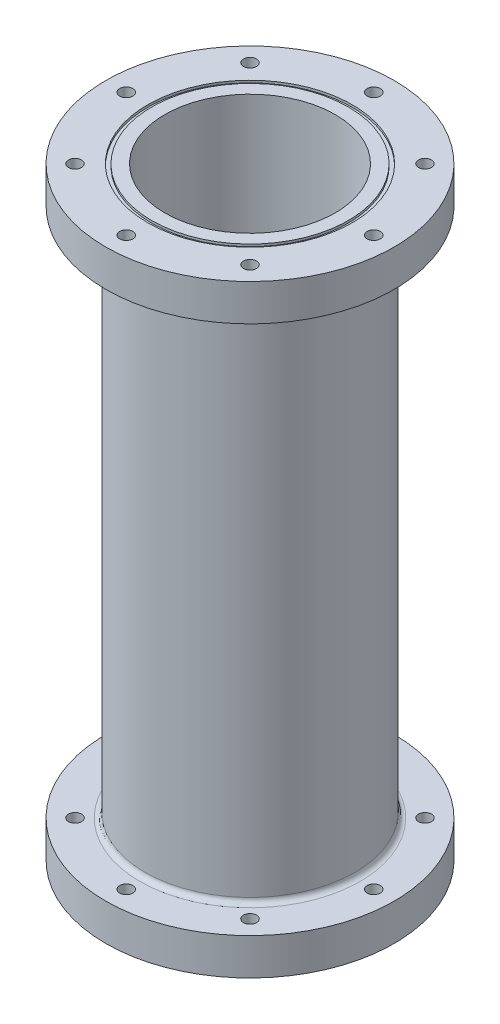
from build123d import *

# Parameters (mm, degrees)
SKETCH2_R               = 50.8
SKETCH2_R_2             = 41.275
BASE_CYLINDER_DEPTH     = 292.1
SKETCH3_R               = 69.85
SKETCH3_R_2             = 41.275
AFT_FLANGE_DEPTH        = 17.78
SKETCH4_R               = 69.85
SKETCH4_R_2             = 41.275
FORWARD_FLANGE_DEPTH    = 17.78
SKETCH6_R               = 49.53
SKETCH6_R_2             = 47.625
O_RING_SLOT_1_DEPTH     = 1.1176
SKETCH7_R               = 49.53
SKETCH7_R_2             = 47.625
O_RING_SLOT_2_DEPTH     = 1.1176
SKETCH8_R               = 3.175
CUT_EXTRUDE4_DEPTH      = 1
CUT_EXTRUDE4_DEPTH_BACK = 293.1
FILLET1_R               = 2.54


with BuildPart() as part:
    # Sketch2 → Base Cylinder (new body)
    with BuildSketch(Plane(origin=(0, 0, 0), x_dir=(1, 0, 0), z_dir=(0, 1, 0))):
        Circle(SKETCH2_R)
        Circle(SKETCH2_R_2, mode=Mode.SUBTRACT)
    extrude(amount=BASE_CYLINDER_DEPTH)

    # Sketch3 → Aft Flange (add)
    with BuildSketch(Plane.XZ):
        Circle(SKETCH3_R)
        Circle(SKETCH3_R_2, mode=Mode.SUBTRACT)
    extrude(amount=-AFT_FLANGE_DEPTH)

    # Sketch4 → Forward Flange (add)
    with BuildSketch(Plane(origin=(0, 292.1, 0), x_dir=(1, 0, 0), z_dir=(0, 1, 0))):
        Circle(SKETCH4_R)
        Circle(SKETCH4_R_2, mode=Mode.SUBTRACT)
    extrude(amount=-FORWARD_FLANGE_DEPTH)

    # Sketch6 → O-Ring Slot 1 (cut)
    with BuildSketch(Plane.XZ):
        Circle(SKETCH6_R)
        Circle(SKETCH6_R_2, mode=Mode.SUBTRACT)
    extrude(amount=-O_RING_SLOT_1_DEPTH, mode=Mode.SUBTRACT)

    # Sketch7 → O-Ring Slot 2 (cut)
    with BuildSketch(Plane(origin=(0, 292.1, 0), x_dir=(1, 0, 0), z_dir=(0, 1, 0))):
        Circle(SKETCH7_R)
        Circle(SKETCH7_R_2, mode=Mode.SUBTRACT)
    extrude(amount=-O_RING_SLOT_2_DEPTH, mode=Mode.SUBTRACT)

    # Sketch8 → Cut-Extrude4 (cut, two sides)
    with BuildSketch(Plane.XZ) as cut_extrude4_sk:
        with Locations((-59.9186, 0)):
            Circle(SKETCH8_R)
        with Locations((-42.368848379, 42.368848379)):
            Circle(SKETCH8_R)
        with Locations((0, 59.9186)):
            Circle(SKETCH8_R)
        with Locations((42.368848379, 42.368848379)):
            Circle(SKETCH8_R)
        with Locations((59.9186, 0)):
            Circle(SKETCH8_R)
        with Locations((42.368848379, -42.368848379)):
            Circle(SKETCH8_R)
        with Locations((0, -59.9186)):
            Circle(SKETCH8_R)
        with Locations((-42.368848379, -42.368848379)):
            Circle(SKETCH8_R)
    extrude(amount=CUT_EXTRUDE4_DEPTH, mode=Mode.SUBTRACT)
    extrude(cut_extrude4_sk.sketch, amount=-CUT_EXTRUDE4_DEPTH_BACK, mode=Mode.SUBTRACT)

    # Fillet1
    fillet1_edges = [part.edges().sort_by_distance(p)[0] for p in [
        (-50.8, 17.78, 0),
        (-50.8, 274.32, 0),
    ]]
    fillet(fillet1_edges, radius=FILLET1_R)


solid = part.part
